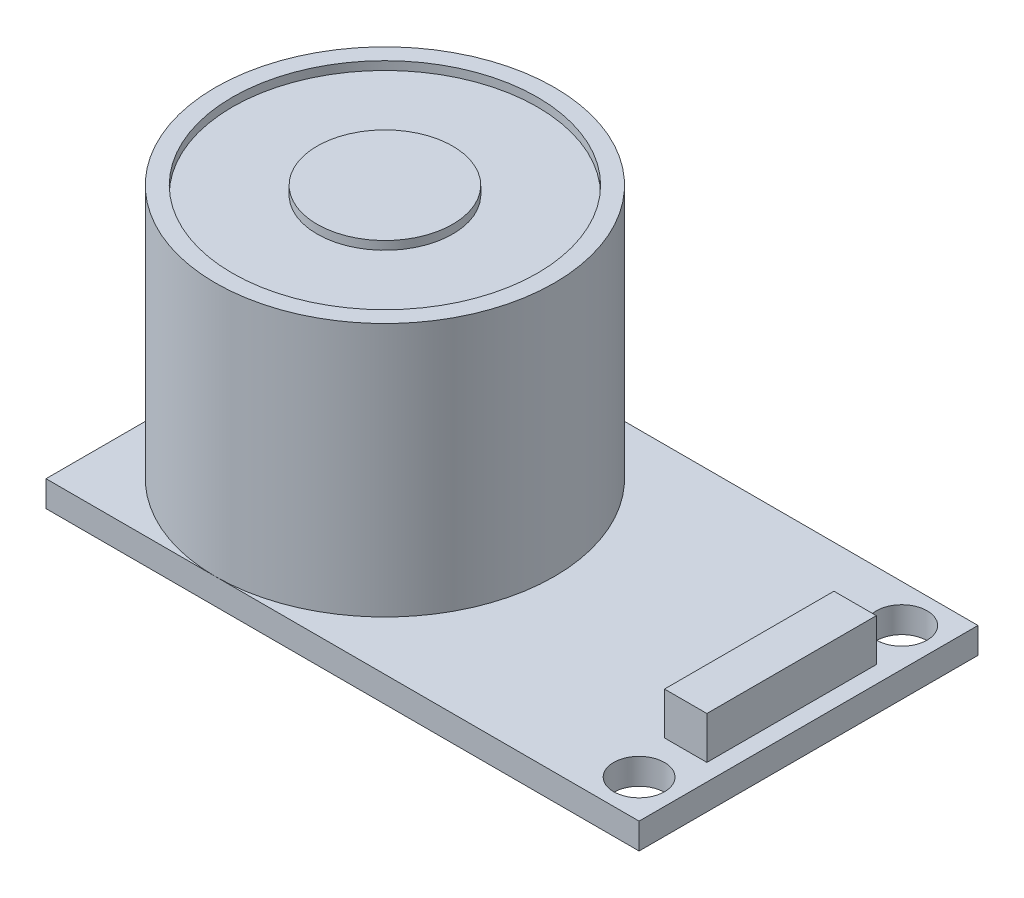
from build123d import *

# Parameters (mm, degrees)
SKETCH1_W           = 35
SKETCH1_H           = 20
SKETCH1_R           = 1.5
BOSS_EXTRUDE1_DEPTH = 1.53
SKETCH2_R           = 10
BOSS_EXTRUDE2_DEPTH = 15
SKETCH3_R           = 9
SKETCH3_R_2         = 4
CUT_EXTRUDE1_DEPTH  = 0.5
SKETCH4_W           = 2.5
SKETCH4_H           = 10
BOSS_EXTRUDE3_DEPTH = 2.5


with BuildPart() as part:
    # Sketch1 → Boss-Extrude1 (new body)
    with BuildSketch(Plane(origin=(0, 0, 0), x_dir=(1, 0, 0), z_dir=(0, 1, 0))):
        with Locations((17.5, 10)):
            Rectangle(SKETCH1_W, SKETCH1_H)
        with Locations((32.75, 17.75)):
            Circle(SKETCH1_R, mode=Mode.SUBTRACT)
        with Locations((32.75, 2.25)):
            Circle(SKETCH1_R, mode=Mode.SUBTRACT)
    extrude(amount=BOSS_EXTRUDE1_DEPTH)

    # Sketch2 → Boss-Extrude2 (add)
    with BuildSketch(Plane(origin=(0, 1.53, 0), x_dir=(1, 0, 0), z_dir=(0, 1, 0))):
        with Locations((10, 10)):
            Circle(SKETCH2_R)
    extrude(amount=BOSS_EXTRUDE2_DEPTH)

    # Sketch3 → Cut-Extrude1 (cut)
    with BuildSketch(Plane(origin=(0, 16.53, 0), x_dir=(1, 0, 0), z_dir=(0, 1, 0))):
        with Locations((10, 10)):
            Circle(SKETCH3_R)
        with Locations((10, 10)):
            Circle(SKETCH3_R_2, mode=Mode.SUBTRACT)
    extrude(amount=-CUT_EXTRUDE1_DEPTH, mode=Mode.SUBTRACT)

    # Sketch4 → Boss-Extrude3 (add)
    with BuildSketch(Plane(origin=(0, 1.53, 0), x_dir=(1, 0, 0), z_dir=(0, 1, 0))):
        with Locations((32.75, 10)):
            Rectangle(SKETCH4_W, SKETCH4_H)
    extrude(amount=BOSS_EXTRUDE3_DEPTH)


solid = part.part
